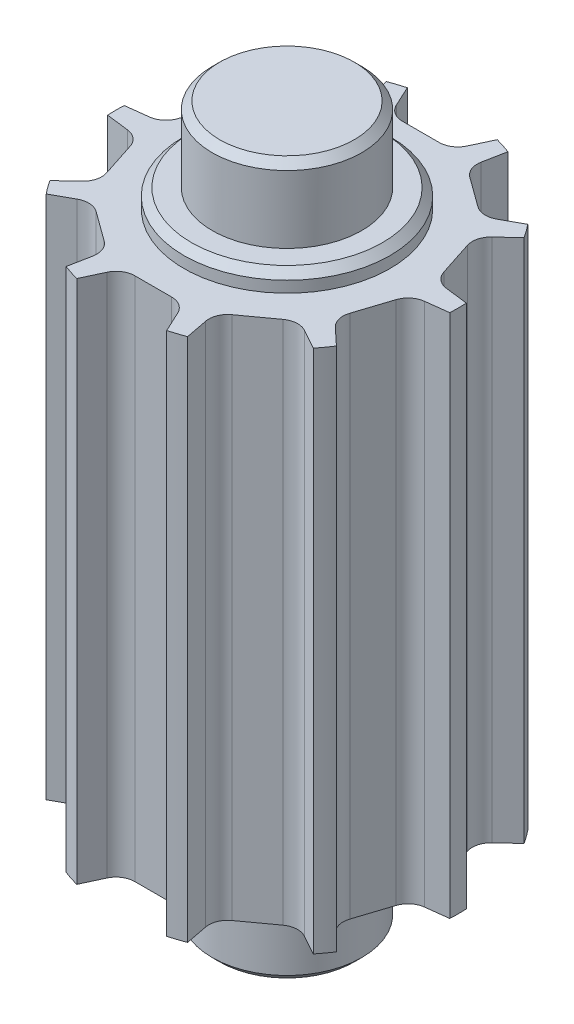
from build123d import *

# Parameters (mm, degrees)
SKIZZE1_R                       = 4.57
AUFSATZ_LINEAR_AUSTRAGEN1_DEPTH = 19
SCHNITT_LINEAR_AUSTRAGEN1_DEPTH = 21.069125541
VERRUNDUNG1_R                   = 0.5
KREISMUSTER1_COUNT              = 10
VERRUNDUNG1_OF_KREISMUSTER1_R   = 0.5
FASE1_SIZE                      = 0.2


with BuildPart() as part:
    # Skizze1 → Aufsatz-Linear austragen1 (new body)
    with BuildSketch(Plane(origin=(0, 0, 0), x_dir=(1, 0, 0), z_dir=(0, 1, 0))):
        Circle(SKIZZE1_R)
    extrude(amount=AUFSATZ_LINEAR_AUSTRAGEN1_DEPTH)

    # Skizze12 → Schnitt-Linear austragen1 (cut, through all)
    with BuildSketch(Plane(origin=(0, 19, 0), x_dir=(1, 0, 0), z_dir=(0, 1, 0))):
        with BuildLine():
            Line((-1.2, 4.409637173), (-0.808470756, 3.57))
            Line((-0.808470756, 3.57), (0.808470756, 3.57))
            Line((0.808470756, 3.57), (1.2, 4.409637173))
            ThreePointArc((1.2, 4.409637173), (0, 4.57), (-1.2, 4.409637173))
        make_face()
    schnitt_linear_austragen1 = extrude(amount=-SCHNITT_LINEAR_AUSTRAGEN1_DEPTH, mode=Mode.SUBTRACT)

    # Verrundung1
    verrundung1_edges = [part.edges().sort_by_distance(p)[0] for p in [
        (-0.808470756, 9.5, -3.57),
        (0.808470756, 9.5, -3.57),
    ]]
    fillet(verrundung1_edges, radius=VERRUNDUNG1_R)

    # Kreismuster1: Schnitt-Linear austragen1 ×10 about axis
    kreismuster1_axis = Axis((0, -1.826859831, 0), (0, 1, 0))
    for i in range(1, KREISMUSTER1_COUNT):
        add(schnitt_linear_austragen1.rotate(kreismuster1_axis, i * 360 / KREISMUSTER1_COUNT), mode=Mode.SUBTRACT)

    # Verrundung1 of Kreismuster1
    verrundung1_of_kreismuster1_edges = [part.edges().sort_by_distance(p)[0] for p in [
        (-2.752459932, 9.5, -2.412983483),
        (-1.44432677, 9.5, -3.363397857),
        (-3.645102966, 9.5, -0.334289289),
        (-3.14544056, 9.5, -1.872092051),
        (-3.14544056, 9.5, 1.872092051),
        (-3.645102966, 9.5, 0.334289289),
        (-1.44432677, 9.5, 3.363397857),
        (-2.752459932, 9.5, 2.412983483),
        (0.808470756, 9.5, 3.57),
        (-0.808470756, 9.5, 3.57),
        (2.752459932, 9.5, 2.412983483),
        (1.44432677, 9.5, 3.363397857),
        (3.645102966, 9.5, 0.334289289),
        (3.14544056, 9.5, 1.872092051),
        (3.14544056, 9.5, -1.872092051),
        (3.645102966, 9.5, -0.334289289),
        (1.44432677, 9.5, -3.363397857),
        (2.752459932, 9.5, -2.412983483),
    ]]
    fillet(verrundung1_of_kreismuster1_edges, radius=VERRUNDUNG1_OF_KREISMUSTER1_R)

    # Skizze13 → Schnitt-Rotation1 (revolve, cut)
    with BuildSketch(Plane(origin=(0, 0, 0), x_dir=(0, 0, -1), z_dir=(1, 0, 0))):
        Polygon((-1.995, 0), (-10.076763041, 0), (-10.076763041, 19), (-1.995, 19), (-1.995, 17), (-2.75, 17), (-2.75, 16.5), (-6.450923694, 16.5), (-6.450923694, 2.5), (-2.75, 2.5), (-2.75, 2), (-1.995, 2), align=None)
    revolve(axis=Axis((0, -5.607699778, 0), (0, 1, 0)), mode=Mode.SUBTRACT)

    # Fase1
    fase1_edges = [part.edges().sort_by_distance(p)[0] for p in [
        (0, 0, -1.995),
        (0, 2, -2.75),
        (0, 17, -2.75),
        (0, 19, -1.995),
    ]]
    chamfer(fase1_edges, length=FASE1_SIZE)

    # Skizze14 → Schnitt-Rotation2 (revolve, cut)
    with BuildSketch(Plane(origin=(0, 0, 0), x_dir=(0, 0, -1), z_dir=(1, 0, 0))):
        Polygon((0, 0), (-0.6, 0), (-0.6, 1.5), (0, 1.748528137), align=None)
    revolve(axis=Axis((0, -2.816169131, 0), (0, 1, 0)), mode=Mode.SUBTRACT)


solid = part.part
